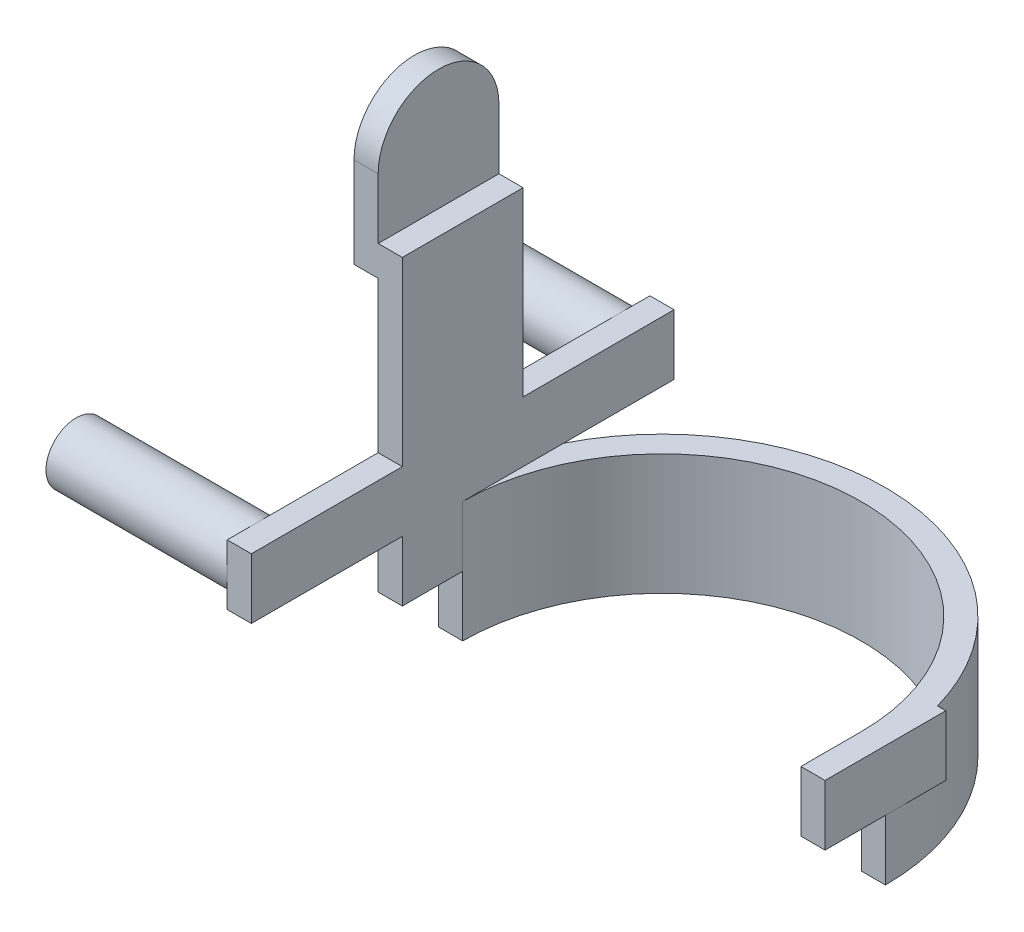
from build123d import *

# Parameters (mm, degrees)
EXTRUDE_1_DEPTH     = 40
SKETCH_2_W          = 8
SKETCH_2_H          = 40
EXTRUDE_2_DEPTH     = 80
SKETCH_5_W          = 87.00766185
SKETCH_5_H          = 115.01495327
CUT_EXTRUDE_2_DEPTH = 10
SKETCH_6_R          = 85.063361003
CUT_EXTRUDE_3_DEPTH = 20
SKETCH_7_W          = 140
SKETCH_7_H          = 20
EXTRUDE_3_DEPTH     = 8
SKETCH_9_R          = 10
EXTRUDE_4_DEPTH     = 60
SKETCH_10_W         = 8
SKETCH_10_H         = 50
EXTRUDE_5_DEPTH     = 40
CUT_EXTRUDE_4_DEPTH = 40


with BuildPart() as part:
    # 草图1 → 凸台-拉伸1 (new body)
    with BuildSketch(Plane(origin=(0, 0, 0), x_dir=(1, 0, 0), z_dir=(0, 1, 0))):
        with BuildLine():
            Line((-74, 20), (-71.246052522, 20))
            ThreePointArc((-71.246052522, 20), (0, 74), (71.246052522, 20))
            Line((71.246052522, 20), (74, 20))
            Line((74, 20), (74, -20))
            Line((74, -20), (66, -20))
            Line((66, -20), (66, 0))
            ThreePointArc((66, 0), (0, 66), (-66, 0))
            Line((-66, 0), (-66, -20))
            Line((-66, -20), (-74, -20))
            Line((-74, -20), (-74, 20))
        make_face()
    extrude(amount=EXTRUDE_1_DEPTH)

    # 草图2 → 凸台-拉伸2 (add)
    with BuildSketch(Plane(origin=(0, 40, 0), x_dir=(1, 0, 0), z_dir=(0, 1, 0))):
        with Locations((-70, 0)):
            Rectangle(SKETCH_2_W, SKETCH_2_H)
        with Locations((70, 0)):
            Rectangle(SKETCH_2_W, SKETCH_2_H)
    extrude(amount=EXTRUDE_2_DEPTH)

    # 草图5 → 切除-拉伸2 (cut)
    with BuildSketch(Plane(origin=(74, 0, 0), x_dir=(0, 0, -1), z_dir=(1, 0, 0))):
        with Locations((-23.503830925, 97.507476635)):
            Rectangle(SKETCH_5_W, SKETCH_5_H)
    extrude(amount=-CUT_EXTRUDE_2_DEPTH, mode=Mode.SUBTRACT)

    # 草图6 → 切除-拉伸3 (cut)
    with BuildSketch(Plane.XZ):
        Circle(SKETCH_6_R)
        with BuildLine():
            Line((-71.246052522, 20), (-66, 20))
            Line((-66, 20), (-66, 0))
            Line((-66, 0), (-74, 0))
            ThreePointArc((-74, 0), (0, -74), (74, 0))
            Line((74, 0), (66, 0))
            Line((66, 0), (66, 20))
            Line((66, 20), (71.246052522, 20))
            ThreePointArc((71.246052522, 20), (0, 74), (-71.246052522, 20))
        make_face(mode=Mode.SUBTRACT)
    extrude(amount=-CUT_EXTRUDE_3_DEPTH, mode=Mode.SUBTRACT)

    # 草图7 → 凸台-拉伸3 (add)
    with BuildSketch(Plane.ZY.offset(74)):
        with Locations((0, 50)):
            Rectangle(SKETCH_7_W, SKETCH_7_H)
    extrude(amount=-EXTRUDE_3_DEPTH)

    # 草图9 → 凸台-拉伸4 (add)
    with BuildSketch(Plane.ZY.offset(74)):
        with Locations((-60, 50)):
            Circle(SKETCH_9_R)
        with Locations((60, 50)):
            Circle(SKETCH_9_R)
    extrude(amount=EXTRUDE_4_DEPTH)

    # 草图10 → 凸台-拉伸5 (add)
    with BuildSketch(Plane.XY.offset(20)):
        with Locations((-78, 135)):
            Rectangle(SKETCH_10_W, SKETCH_10_H)
    extrude(amount=-EXTRUDE_5_DEPTH)

    # 草图11 → 切除-拉伸4 (cut)
    with BuildSketch(Plane.ZY.offset(82)):
        with BuildLine():
            Line((-20, 140), (-20, 168.258518719))
            Line((-20, 168.258518719), (20, 168.258518719))
            Line((20, 168.258518719), (20, 140))
            ThreePointArc((20, 140), (0, 160), (-20, 140))
        make_face()
    extrude(amount=-CUT_EXTRUDE_4_DEPTH, mode=Mode.SUBTRACT)


solid = part.part
